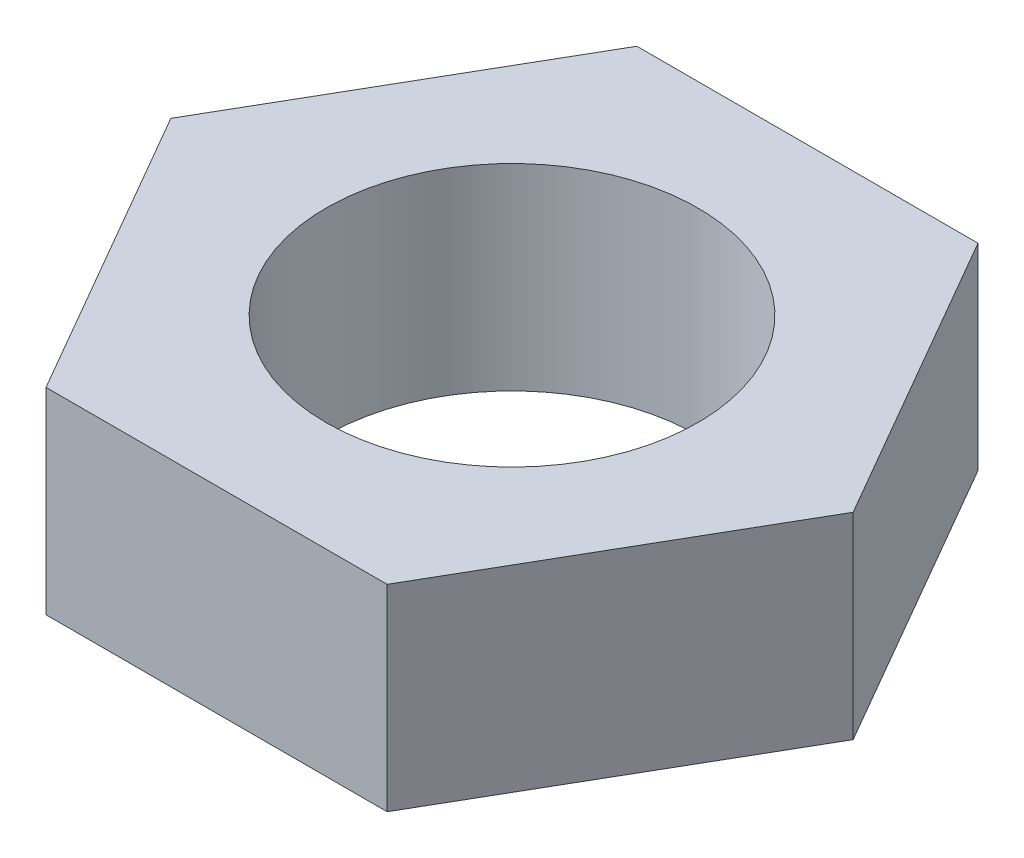
from build123d import *

# Parameters (mm, degrees)
SKETCH1_R           = 1.4986
BOSS_EXTRUDE1_DEPTH = 1.5875


with BuildPart() as part:
    # Sketch1 → Boss-Extrude1 (new body)
    with BuildSketch(Plane(origin=(0, 0, 0), x_dir=(1, 0, 0), z_dir=(0, 1, 0))):
        Polygon((1.374815329, 2.38125), (-1.374815329, 2.38125), (-2.749630657, 0), (-1.374815329, -2.38125), (1.374815329, -2.38125), (2.749630657, 0), align=None)
        Circle(SKETCH1_R, mode=Mode.SUBTRACT)
    extrude(amount=BOSS_EXTRUDE1_DEPTH)


solid = part.part
